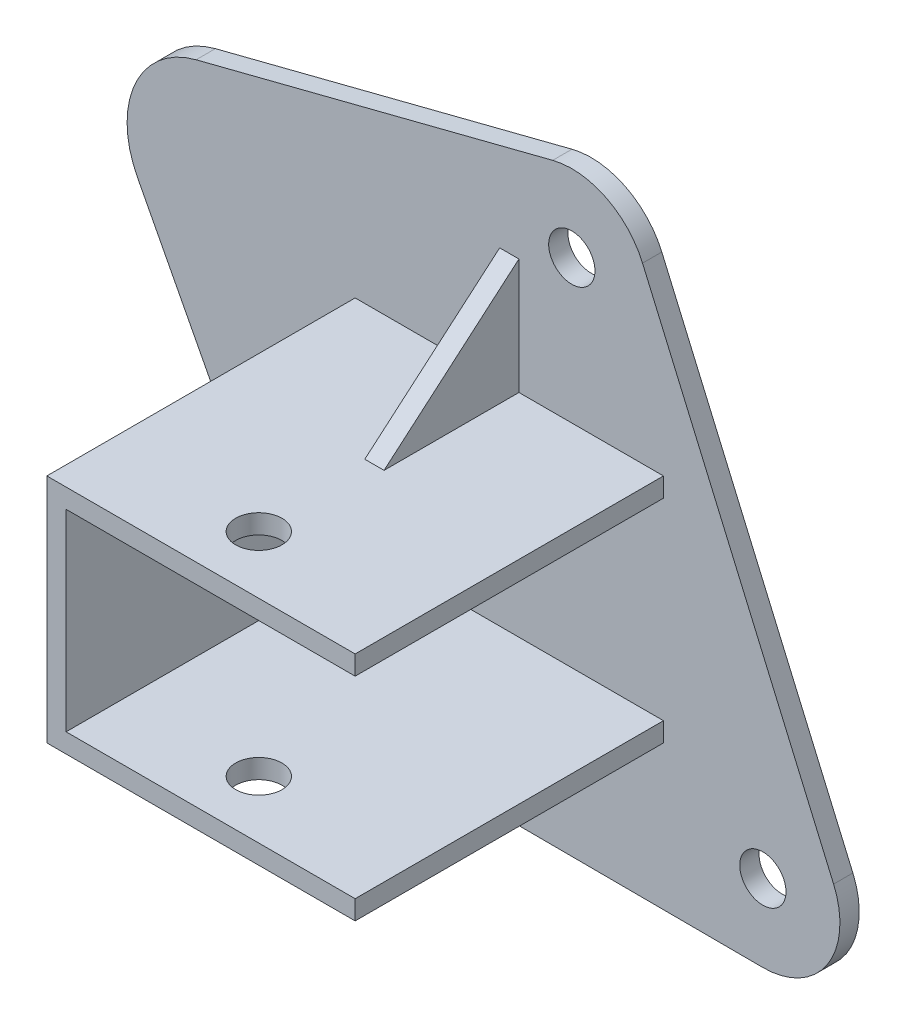
from build123d import *

# Parameters (mm, degrees)
ESQUISSE1_W             = 272.524799983
ESQUISSE1_H             = 173.408070163
ESQUISSE1_R             = 6
BOSS_EXTRU_1_DEPTH      = 5
ESQUISSE2_OUTSIDE_W     = 339.137
ESQUISSE2_OUTSIDE_H     = 240.02
ENL_V_MAT_EXTRU_1_DEPTH = 5
BOSS_EXTRU_2_DEPTH      = 80
ESQUISSE4_R             = 6
ENL_V_MAT_EXTRU_2_DEPTH = 98.574759668
BOSS_EXTRU_3_DEPTH      = 2.5


with BuildPart() as part:
    # Esquisse1 → Boss.-Extru.1 (new body)
    with BuildSketch(Plane.XY):
        with Locations((-544.151755804, 61.14332382)):
            Rectangle(ESQUISSE1_W, ESQUISSE1_H)
        with Locations((-580.420844254, 0.36763792)):
            Circle(ESQUISSE1_R, mode=Mode.SUBTRACT)
        with Locations((-480.421520044, 0)):
            Circle(ESQUISSE1_R, mode=Mode.SUBTRACT)
        with Locations((-530, 114.747437119)):
            Circle(ESQUISSE1_R, mode=Mode.SUBTRACT)
    extrude(amount=BOSS_EXTRU_1_DEPTH)

    # Esquisse2 outside → Enlèv. mat.-Extru.1 (cut)
    with BuildSketch(Plane.XY.offset(5)):
        with Locations((-544.1515, 61.143)):
            Rectangle(ESQUISSE2_OUTSIDE_W, ESQUISSE2_OUTSIDE_H)
        with BuildLine():
            Line((-534.956009313, 134.12365893), (-627.481332722, 110.457726071))
            ThreePointArc((-627.481332722, 110.457726071), (-643.319491193, 97.095160735), (-642.680296555, 76.382921688))
            Line((-642.680296555, 76.382921688), (-598.149058477, -8.890354328))
            ThreePointArc((-598.149058477, -8.890354328), (-590.816634727, -16.718249252), (-580.494371838, -19.632226922))
            Line((-580.494371838, -19.632226922), (-480.495047628, -19.999864842))
            ThreePointArc((-480.495047628, -19.999864842), (-463.728705311, -11.015894711), (-462.061930105, 7.932556793))
            Line((-462.061930105, 7.932556793), (-511.640410061, 122.679993912))
            ThreePointArc((-511.640410061, 122.679993912), (-521.187885573, 132.701451693), (-534.956009313, 134.12365893))
        make_face(mode=Mode.SUBTRACT)
    extrude(amount=-ENL_V_MAT_EXTRU_1_DEPTH, mode=Mode.SUBTRACT)

    # Esquisse3 → Boss.-Extru.2 (add)
    with BuildSketch(Plane.XY.offset(5)):
        Polygon((-586.213116183, 77.574759668), (-506.213116183, 77.574759668), (-506.213116183, 72.574759668), (-581.213116183, 72.574759668), (-581.213116183, 22.574759668), (-506.213116183, 22.574759668), (-506.213116183, 17.574759668), (-586.213116183, 17.574759668), (-586.213116183, 22.574759668), (-586.213116183, 72.574759668), align=None)
    extrude(amount=BOSS_EXTRU_2_DEPTH)

    # Esquisse4 → Enlèv. mat.-Extru.2 (cut, through all)
    with BuildSketch(Plane(origin=(0, 77.574759668, 0), x_dir=(1, 0, 0), z_dir=(0, 1, 0))):
        with Locations(Location((-546.213116183, -70, 0), (0, 0, 270))):  # turned: the seam where the file's is
            Circle(ESQUISSE4_R)
    extrude(amount=-ENL_V_MAT_EXTRU_2_DEPTH, mode=Mode.SUBTRACT)

    # Esquisse5 → Boss.-Extru.3 (add, symmetric)
    with BuildSketch(Plane.ZY.offset(546.213116183)):
        Polygon((5, 107.574759668), (40, 77.574759668), (5, 77.574759668), align=None)
        Polygon((5, 17.574759668), (5, -12.425240332), (40, 17.574759668), align=None)
    extrude(amount=BOSS_EXTRU_3_DEPTH, both=True)


solid = part.part
